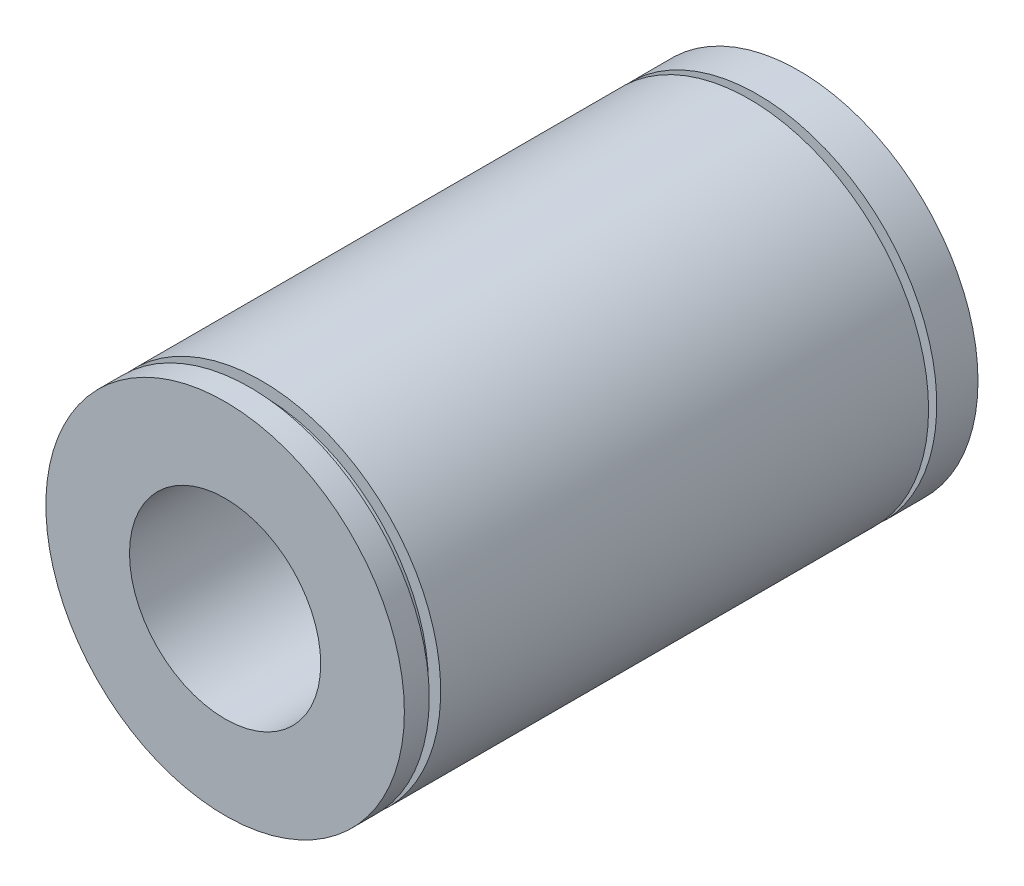
from build123d import *

# Parameters (mm, degrees)
SKETCH_1_R      = 7.5
SKETCH_1_R_2    = 4
EXTRUDE_1_DEPTH = 24
SKETCH_2_W      = 1.02813504
SKETCH_2_H      = 0.342481518
SKETCH_2_H_2    = 0.479474125


with BuildPart() as part:
    # 草图1 → 凸台-拉伸1 (new body)
    with BuildSketch(Plane.XY):
        Circle(SKETCH_1_R)
        Circle(SKETCH_1_R_2, mode=Mode.SUBTRACT)
    extrude(amount=EXTRUDE_1_DEPTH)

    # 草图2 → 切除-旋转1 (revolve, cut)
    with BuildSketch(Plane(origin=(0, 0, 0), x_dir=(1, 0, 0), z_dir=(0, 1, 0))):
        with Locations((7.5, -1.89679522)):
            Rectangle(SKETCH_2_W, SKETCH_2_H)
        with Locations((7.5, -22.719671512)):
            Rectangle(SKETCH_2_W, SKETCH_2_H_2)
    revolve(axis=Axis((0, 0, 0), (0, 0, -1)), mode=Mode.SUBTRACT)


solid = part.part
